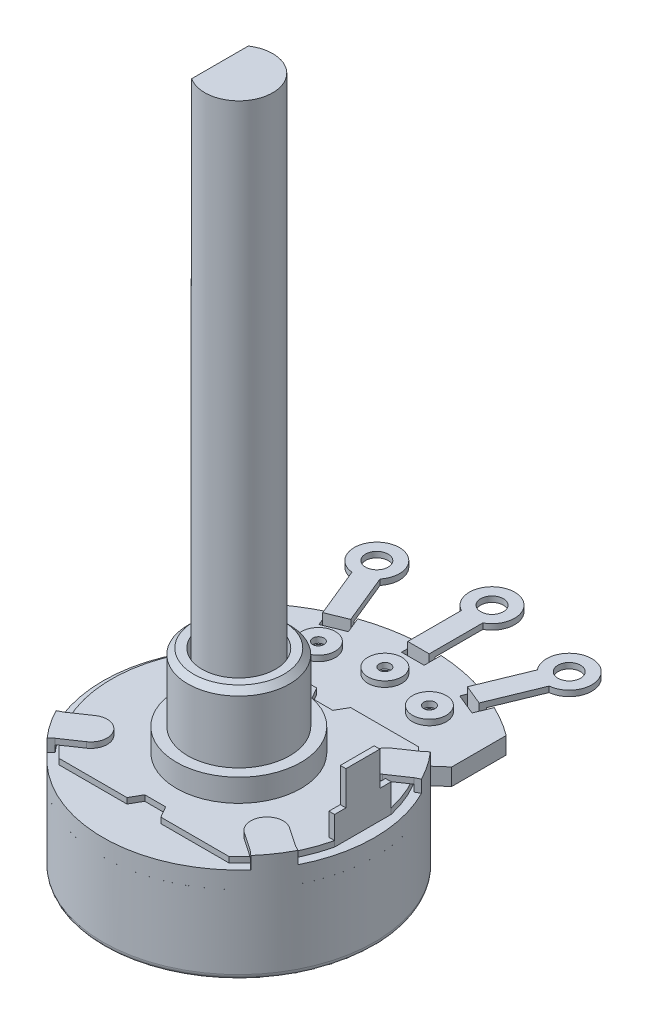
from build123d import *
from build123d.topology import SkipClean

# Parameters (mm, degrees)
SKETCH1_R                 = 12
BOSS_EXTRUDE1_DEPTH       = 7
SKETCH2_R                 = 11.5
CUT_EXTRUDE1_DEPTH        = 6.5
CUT_EXTRUDE2_DEPTH        = 2
SKETCH10_R                = 0.5
BOSS_EXTRUDE2_DEPTH       = 1.5
BOSS_EXTRUDE3_DEPTH       = 2.6
FILLET1_R                 = 0.5
BOSS_EXTRUDE4_DEPTH       = 0.5
SKETCH15_W                = 0.5
SKETCH15_H                = 5
BOSS_EXTRUDE5_DEPTH       = 2
CUT_EXTRUDE7_DEPTH        = 0.51
SKETCH18_W                = 0.5
SKETCH18_H                = 3
BOSS_EXTRUDE6_DEPTH       = 3
SKETCH19_W                = 2.879262998
SKETCH19_H                = 0.5
BOSS_EXTRUDE7_DEPTH       = 2
BOSS_EXTRUDE7_DEPTH_BACK  = 0.25
BOSS_EXTRUDE8_DEPTH       = 0.5
SKETCH34_W                = 2.879262998
SKETCH34_H                = 0.5
BOSS_EXTRUDE18_DEPTH      = 2
BOSS_EXTRUDE18_DEPTH_BACK = 0.3
SKETCH35_W                = 2.879262998
SKETCH35_H                = 0.5
BOSS_EXTRUDE19_DEPTH      = 2
BOSS_EXTRUDE19_DEPTH_BACK = 0.25
SKETCH36_W                = 2.879262998
SKETCH36_H                = 0.5
BOSS_EXTRUDE20_DEPTH      = 0.25
BOSS_EXTRUDE20_DEPTH_BACK = 2
BOSS_EXTRUDE21_DEPTH      = 0.5
SKETCH22_R                = 5.5
BOSS_EXTRUDE9_DEPTH       = 2
SKETCH23_R                = 4.5
SKETCH23_R_2              = 3.25
BOSS_EXTRUDE10_DEPTH      = 6
CHAMFER1_SIZE             = 0.5
SKETCH24_R                = 3
BOSS_EXTRUDE11_DEPTH      = 50
CUT_EXTRUDE8_DEPTH        = 16
BOSS_EXTRUDE12_DEPTH      = 0.5
SKETCH27_W                = 1.9
SKETCH27_H                = 0.5
BOSS_EXTRUDE13_DEPTH      = 2.1
SKETCH28_W                = 1.9
SKETCH28_H                = 0.5
BOSS_EXTRUDE14_DEPTH      = 8
SKETCH29_W                = 1.9
SKETCH29_H                = 0.5
BOSS_EXTRUDE15_DEPTH      = 8
SKETCH30_W                = 1.9
SKETCH30_H                = 0.5
BOSS_EXTRUDE16_DEPTH      = 8
SKETCH31_R                = 2
SKETCH31_R_2              = 1.5
SKETCH31_R_3              = 0.5
BOSS_EXTRUDE17_DEPTH      = 0.5
SKETCH33_R                = 1
SKETCH33_R_2              = 0.5
CUT_EXTRUDE9_DEPTH        = 59.592949152


with BuildPart() as part:
    # Sketch1 → Boss-Extrude1 (new body)
    with BuildSketch(Plane(origin=(0, 0, 0), x_dir=(1, 0, 0), z_dir=(0, 1, 0))):
        with Locations(Location((0, 0, 0), (0, 0, 270))):
            Circle(SKETCH1_R)
    extrude(amount=BOSS_EXTRUDE1_DEPTH)

    # Sketch2 → Cut-Extrude1 (cut)
    with BuildSketch(Plane(origin=(0, 7, 0), x_dir=(1, 0, 0), z_dir=(0, 1, 0))):
        with Locations(Location((0, 0, 0), (0, 0, 270))):
            Circle(SKETCH2_R)
    extrude(amount=-CUT_EXTRUDE1_DEPTH, mode=Mode.SUBTRACT)

    # Sketch3 → Cut-Extrude2 (cut)
    with BuildSketch(Plane(origin=(0, 7, 0), x_dir=(1, 0, 0), z_dir=(0, 1, 0))):
        with BuildLine():
            Line((-9, 7.937253933), (0, 0))
            Line((0, 0), (9, 7.937253933))
            ThreePointArc((9, 7.937253933), (0, 12), (-9, 7.937253933))
        make_face()
    extrude(amount=-CUT_EXTRUDE2_DEPTH, mode=Mode.SUBTRACT)



with BuildPart() as body_2:
    # Sketch10 → Boss-Extrude2 (new body)
    with BuildSketch(Plane(origin=(0, 7.001, 0), x_dir=(1, 0, 0), z_dir=(0, 1, 0))):
        with BuildLine():
            Line((-10.2421875, 5.229492826), (-10.6875, 5.456862079))
            ThreePointArc((-10.6875, 5.456862079), (-12, 0), (-10.6875, -5.456862079))
            Line((-10.6875, -5.456862079), (-10.2421875, -5.229492826))
            ThreePointArc((-10.2421875, -5.229492826), (-9.508168774, -6.46875), (-8.625, -7.606535019))
            Line((-8.625, -7.606535019), (-9, -7.937253933))
            ThreePointArc((-9, -7.937253933), (0, -12), (9, -7.937253933))
            Line((9, -7.937253933), (8.625, -7.606535019))
            ThreePointArc((8.625, -7.606535019), (9.508168774, -6.46875), (10.2421875, -5.229492826))
            Line((10.2421875, -5.229492826), (10.6875, -5.456862079))
            ThreePointArc((10.6875, -5.456862079), (12, 0), (10.6875, 5.456862079))
            Line((10.6875, 5.456862079), (10.2421875, 5.229492826))
            ThreePointArc((10.2421875, 5.229492826), (9.508168774, 6.46875), (8.625, 7.606535019))
            Line((8.625, 7.606535019), (9, 7.937253933))
            Line((9, 7.937253933), (10, 8.819171037))
            Line((10, 8.819171037), (10, 13.6383453))
            ThreePointArc((10, 13.6383453), (8.706156522, 14.498527551), (7.33883105, 15.236338843))
            Line((7.33883105, 15.236338843), (6.768953445, 13.848808838))
            Line((6.768953445, 13.848808838), (4.918913438, 14.608645644))
            Line((4.918913438, 14.608645644), (5.488791042, 15.99617565))
            ThreePointArc((5.488791042, 15.99617565), (3.274493365, 16.591629086), (1, 16.882075184))
            Line((1, 16.882075184), (1, 15.382075184))
            Line((1, 15.382075184), (-1, 15.382075184))
            Line((-1, 15.382075184), (-1, 16.882075184))
            ThreePointArc((-1, 16.882075184), (-3.274493365, 16.591629086), (-5.488791042, 15.99617565))
            Line((-5.488791042, 15.99617565), (-4.918913438, 14.608645644))
            Line((-4.918913438, 14.608645644), (-6.768953445, 13.848808838))
            Line((-6.768953445, 13.848808838), (-7.33883105, 15.236338843))
            ThreePointArc((-7.33883105, 15.236338843), (-8.706156522, 14.498527551), (-10, 13.6383453))
            Line((-10, 13.6383453), (-10, 8.819171037))
            Line((-10, 8.819171037), (-9, 7.937253933))
            Line((-9, 7.937253933), (-8.625, 7.606535019))
            ThreePointArc((-8.625, 7.606535019), (-9.508168774, 6.46875), (-10.2421875, 5.229492826))
        make_face()
        with Locations(Location((0, 12.911666462, 0), (0, 0, 270))):
            Circle(SKETCH10_R, mode=Mode.SUBTRACT)
        with Locations(Location((-4.905379704, 11.943549756, 0), (0, 0, 270))):
            Circle(SKETCH10_R, mode=Mode.SUBTRACT)
        with Locations(Location((4.905379704, 11.943549756, 0), (0, 0, 270))):
            Circle(SKETCH10_R, mode=Mode.SUBTRACT)
    extrude(amount=BOSS_EXTRUDE2_DEPTH)


with BuildPart() as part_1:
    with SkipClean():  # the faces are left unmerged after this step: merging them gives an invalid solid
        add(part.part)

        add(body_2.part)  # Boss-Extrude3 merges body 2
        # Sketch11 → Boss-Extrude3 (add)
        with BuildSketch(Plane(origin=(0, 7, 0), x_dir=(1, 0, 0), z_dir=(0, 1, 0))):
            with BuildLine():
                Line((8.625, 7.606535019), (9, 7.937253933))
                ThreePointArc((9, 7.937253933), (9.922828246, 6.748146383), (10.689538103, 5.452868525))
                Line((10.689538103, 5.452868525), (10.244140682, 5.225665669))
                ThreePointArc((10.244140682, 5.225665669), (9.509377069, 6.466973617), (8.625, 7.606535019))
            make_face()
            with BuildLine():
                Line((8.625, -7.606535019), (9, -7.937253933))
                ThreePointArc((9, -7.937253933), (9.922828246, -6.748146383), (10.689538103, -5.452868525))
                Line((10.689538103, -5.452868525), (10.244140682, -5.225665669))
                ThreePointArc((10.244140682, -5.225665669), (9.509377069, -6.466973617), (8.625, -7.606535019))
            make_face()
            with BuildLine():
                Line((-8.625, -7.606535019), (-9, -7.937253933))
                ThreePointArc((-9, -7.937253933), (-9.922828246, -6.748146383), (-10.689538103, -5.452868525))
                Line((-10.689538103, -5.452868525), (-10.244140682, -5.225665669))
                ThreePointArc((-10.244140682, -5.225665669), (-9.509377069, -6.466973617), (-8.625, -7.606535019))
            make_face()
            with BuildLine():
                Line((-10.689538103, 5.452868525), (-10.244140682, 5.225665669))
                ThreePointArc((-10.244140682, 5.225665669), (-9.509377069, 6.466973617), (-8.625, 7.606535019))
                Line((-8.625, 7.606535019), (-9, 7.937253933))
                ThreePointArc((-9, 7.937253933), (-9.922828246, 6.748146383), (-10.689538103, 5.452868525))
            make_face()
        extrude(amount=BOSS_EXTRUDE3_DEPTH)

    # Fillet1
    fillet1_edges = [part_1.edges().sort_by_distance(p)[0] for p in [
        (0, 0, -12),
    ]]
    fillet(fillet1_edges, radius=FILLET1_R)



with BuildPart() as body_2_2:
    # Sketch14 → Boss-Extrude4 (new body)
    with BuildSketch(Plane(origin=(0, 8.511, 0), x_dir=(1, 0, 0), z_dir=(0, 1, 0))):
        with BuildLine():
            Line((-7.5, 8.385254916), (-1.5, 8.385254916))
            Line((-1.5, 8.385254916), (-0.922649731, 7.385254916))
            Line((-0.922649731, 7.385254916), (0.922649731, 7.385254916))
            Line((0.922649731, 7.385254916), (1.5, 8.385254916))
            Line((1.5, 8.385254916), (7.5, 8.385254916))
            ThreePointArc((7.5, 8.385254916), (11.25, 0), (7.5, -8.385254916))
            Line((7.5, -8.385254916), (1.5, -8.385254916))
            Line((1.5, -8.385254916), (0.922649731, -7.385254916))
            Line((0.922649731, -7.385254916), (-0.922649731, -7.385254916))
            Line((-0.922649731, -7.385254916), (-1.5, -8.385254916))
            Line((-1.5, -8.385254916), (-7.5, -8.385254916))
            ThreePointArc((-7.5, -8.385254916), (-11.25, 0), (-7.5, 8.385254916))
        make_face()
    extrude(amount=BOSS_EXTRUDE4_DEPTH)

    # Sketch15 → Boss-Extrude5 (add)
    with BuildSketch(Plane(origin=(0, 9.011, 0), x_dir=(1, 0, 0), z_dir=(0, 1, 0))):
        with Locations((10.718705484, 0)):
            Rectangle(SKETCH15_W, SKETCH15_H)
    extrude(amount=BOSS_EXTRUDE5_DEPTH)

    # Sketch17 → Cut-Extrude7 (cut)
    with BuildSketch(Plane(origin=(0, 9.011, 0), x_dir=(1, 0, 0), z_dir=(0, 1, 0))):
        Polygon((10.968705484, 72.60744613), (10.968705484, 2.5), (10.968705484, -2.5), (10.968705484, -72.60744613), (151.183597744, -72.60744613), (151.183597744, 72.60744613), align=None)
    extrude(amount=-CUT_EXTRUDE7_DEPTH, mode=Mode.SUBTRACT)

    # Sketch18 → Boss-Extrude6 (add)
    with BuildSketch(Plane(origin=(0, 11.011, 0), x_dir=(1, 0, 0), z_dir=(0, 1, 0))):
        with Locations((10.718705484, 0)):
            Rectangle(SKETCH18_W, SKETCH18_H)
    extrude(amount=BOSS_EXTRUDE6_DEPTH)

    # Sketch22 → Boss-Extrude9 (add)
    with BuildSketch(Plane(origin=(0, 9.011, 0), x_dir=(1, 0, 0), z_dir=(0, 1, 0))):
        with Locations(Location((0, 0, 0), (0, 0, 270))):
            Circle(SKETCH22_R)
    extrude(amount=BOSS_EXTRUDE9_DEPTH)

    # Sketch23 → Boss-Extrude10 (add)
    with BuildSketch(Plane(origin=(0, 11.011, 0), x_dir=(1, 0, 0), z_dir=(0, 1, 0))):
        with Locations(Location((0, 0, 0), (0, 0, 270))):
            Circle(SKETCH23_R)
        with Locations(Location((0, 0, 0), (0, 0, 270))):
            Circle(SKETCH23_R_2, mode=Mode.SUBTRACT)
    extrude(amount=BOSS_EXTRUDE10_DEPTH)

    # Chamfer1
    chamfer1_edges = [body_2_2.edges().sort_by_distance(p)[0] for p in [
        (0, 17.011, -4.5),
    ]]
    chamfer(chamfer1_edges, length=CHAMFER1_SIZE)

    # Sketch24 → Boss-Extrude11 (add)
    with BuildSketch(Plane(origin=(0, 11.011, 0), x_dir=(1, 0, 0), z_dir=(0, 1, 0))):
        with Locations(Location((0, 0, 0), (0, 0, 270))):
            Circle(SKETCH24_R)
    extrude(amount=BOSS_EXTRUDE11_DEPTH)

    # Sketch25 → Cut-Extrude8 (cut)
    with BuildSketch(Plane(origin=(0, 61.011, 0), x_dir=(1, 0, 0), z_dir=(0, 1, 0))):
        with BuildLine():
            Line((-1.658312395, 2.5), (-1.658312395, -2.5))
            ThreePointArc((-1.658312395, -2.5), (-3, 0), (-1.658312395, 2.5))
        make_face()
    extrude(amount=-CUT_EXTRUDE8_DEPTH, mode=Mode.SUBTRACT)


with BuildPart() as body_3:
    # Sketch19 → Boss-Extrude7 (new, two sides)
    with BuildSketch(Plane(origin=(9.434570341, 0, 6.416100344), x_dir=(-0.5623455319339524, 0, 0.8269023537963356), z_dir=(-0.8269023537963356, 0, -0.5623455319339524))) as boss_extrude7_sk:
        with Locations((0, 9.35)):
            Rectangle(SKETCH19_W, SKETCH19_H)
    extrude(amount=BOSS_EXTRUDE7_DEPTH)
    extrude(boss_extrude7_sk.sketch, amount=-BOSS_EXTRUDE7_DEPTH_BACK)


with BuildPart() as part_2:
    with SkipClean():  # the faces are left unmerged after this step: merging them gives an invalid solid
        add(part_1.part)

        add(body_3.part)  # Boss-Extrude8 merges body 3
        # Sketch21 → Boss-Extrude8 (add)
        with BuildSketch(Plane(origin=(0, 9.6, 0), x_dir=(1, 0, 0), z_dir=(0, 1, 0))):
            with BuildLine():
                Line((8.590335974, -4.100974606), (6.971195292, -6.481843955))
                ThreePointArc((6.971195292, -6.481843955), (6.590330958, -4.48183894), (8.590335974, -4.100974606))
            make_face()
        extrude(amount=-BOSS_EXTRUDE8_DEPTH)

    # Sketch35 → Boss-Extrude19 (add, two sides)
    with BuildSketch(Plane(origin=(9.434570341, 0, -6.416100344), x_dir=(0.562345531933952, 0, 0.8269023537963359), z_dir=(-0.826902353796336, 1.3052292315477542e-15, 0.562345531933952))) as boss_extrude19_sk:
        with Locations((0, 9.35)):
            Rectangle(SKETCH35_W, SKETCH35_H)
    extrude(amount=BOSS_EXTRUDE19_DEPTH)
    extrude(boss_extrude19_sk.sketch, amount=-BOSS_EXTRUDE19_DEPTH_BACK)

    # Sketch36 → Boss-Extrude20 (add, two sides)
    with BuildSketch(Plane(origin=(-9.434570341, 0, 6.416100344), x_dir=(0.562345531933952, 0, 0.8269023537963359), z_dir=(-0.826902353796336, 0, 0.562345531933952))) as boss_extrude20_sk:
        with Locations((0, 9.35)):
            Rectangle(SKETCH36_W, SKETCH36_H)
    extrude(amount=BOSS_EXTRUDE20_DEPTH)
    extrude(boss_extrude20_sk.sketch, amount=-BOSS_EXTRUDE20_DEPTH_BACK)



with BuildPart() as body_3_2:
    # Sketch34 → Boss-Extrude18 (new, two sides)
    with BuildSketch(Plane(origin=(-9.434570341, 0, -6.416100344), x_dir=(0.5623455319339522, 0, -0.8269023537963357), z_dir=(0.8269023537963357, 0, 0.5623455319339522))) as boss_extrude18_sk:
        with Locations((0, 9.35)):
            Rectangle(SKETCH34_W, SKETCH34_H)
    extrude(amount=BOSS_EXTRUDE18_DEPTH)
    extrude(boss_extrude18_sk.sketch, amount=-BOSS_EXTRUDE18_DEPTH_BACK)


with BuildPart() as part_3:
    add(part_2.part)

    add(body_3_2.part)  # Boss-Extrude21 merges body 3 2
    # Sketch37 → Boss-Extrude21 (add)
    with BuildSketch(Plane(origin=(0, 9.6, 0), x_dir=(1, 0, 0), z_dir=(0, 1, 0))):
        with BuildLine():
            Line((6.971195292, 6.481843955), (8.590335974, 4.100974606))
            ThreePointArc((8.590335974, 4.100974606), (6.590330958, 4.48183894), (6.971195292, 6.481843955))
        make_face()
        with BuildLine():
            Line((-6.971195292, 6.481843955), (-8.590335974, 4.100974606))
            ThreePointArc((-8.590335974, 4.100974606), (-6.590330958, 4.48183894), (-6.971195292, 6.481843955))
        make_face()
        with BuildLine():
            Line((-8.590335974, -4.100974606), (-6.971195292, -6.481843955))
            ThreePointArc((-6.971195292, -6.481843955), (-6.590330958, -4.48183894), (-8.590335974, -4.100974606))
        make_face()
    extrude(amount=-BOSS_EXTRUDE21_DEPTH)

    # Sketch26 → Boss-Extrude12 (add)
    with BuildSketch(Plane.XZ.offset(-7.001)):
        with BuildLine():
            Line((-5.784148708, -11.582627273), (-7.102620848, -14.792824762))
            Line((-7.102620848, -14.792824762), (-5.345082841, -15.514669728))
            Line((-5.345082841, -15.514669728), (-4.026610701, -12.304472239))
            ThreePointArc((-4.026610701, -12.304472239), (-4.544457221, -11.064780753), (-5.784148708, -11.582627273))
        make_face()
        with BuildLine():
            Line((-0.95, -12.911666462), (-0.95, -16.382075184))
            Line((-0.95, -16.382075184), (0.95, -16.382075184))
            Line((0.95, -16.382075184), (0.95, -12.911666462))
            ThreePointArc((0.95, -12.911666462), (0, -11.961666462), (-0.95, -12.911666462))
        make_face()
        with BuildLine():
            Line((4.026610701, -12.304472239), (5.345082841, -15.514669728))
            Line((5.345082841, -15.514669728), (7.102620848, -14.792824762))
            Line((7.102620848, -14.792824762), (5.784148708, -11.582627273))
            ThreePointArc((5.784148708, -11.582627273), (4.544457221, -11.064780753), (4.026610701, -12.304472239))
        make_face()
    extrude(amount=BOSS_EXTRUDE12_DEPTH)

    # Sketch27 → Boss-Extrude13 (add)
    with BuildSketch(Plane(origin=(0, 7.001, 0), x_dir=(1, 0, 0), z_dir=(0, 1, 0))):
        with Locations((0, 16.132075184)):
            Rectangle(SKETCH27_W, SKETCH27_H)
        Polygon((-5.345082841, 15.514669728), (-5.155123639, 15.052159726), (-6.912661646, 14.33031476), (-7.102620848, 14.792824762), align=None)
        Polygon((7.102620848, 14.792824762), (6.912661646, 14.33031476), (5.155123639, 15.052159726), (5.345082841, 15.514669728), align=None)
    extrude(amount=BOSS_EXTRUDE13_DEPTH)

    # Sketch28 → Boss-Extrude14 (add)
    with BuildSketch(Plane(origin=(6.223851844, 0, -15.153747245), x_dir=(-0.9250200035365485, 0, -0.37991840315684094), z_dir=(0.379918403156841, 0, -0.9250200035365486))):
        with Locations((0, 8.851)):
            Rectangle(SKETCH28_W, SKETCH28_H)
    extrude(amount=BOSS_EXTRUDE14_DEPTH)

    # Sketch29 → Boss-Extrude15 (add)
    with BuildSketch(Plane(origin=(0, 0, -16.382075184), x_dir=(-1, 0, 0), z_dir=(0, 0, -1))):
        with Locations((0, 8.851)):
            Rectangle(SKETCH29_W, SKETCH29_H)
    extrude(amount=BOSS_EXTRUDE15_DEPTH)

    # Sketch30 → Boss-Extrude16 (add)
    with BuildSketch(Plane(origin=(-6.223851844, 0, -15.153747245), x_dir=(-0.9250200035365496, 0, 0.3799184031568382), z_dir=(-0.3799184031568382, 0, -0.9250200035365496))):
        with Locations((0, 8.851)):
            Rectangle(SKETCH30_W, SKETCH30_H)
    extrude(amount=BOSS_EXTRUDE16_DEPTH)

    # Sketch31 → Boss-Extrude17 (add)
    with BuildSketch(Plane(origin=(0, 9.101, 0), x_dir=(1, 0, 0), z_dir=(0, 1, 0))):
        with Locations((8.503362263, 20.703867266)):
            Circle(SKETCH31_R)
        with Locations((0, 22.382075184)):
            Circle(SKETCH31_R)
        with Locations((-8.503362263, 20.703867266)):
            Circle(SKETCH31_R)
        with Locations(Location((-4.905379704, 11.943549756, 0), (0, 0, 270))):
            Circle(SKETCH31_R_2)
        with Locations(Location((-4.905379704, 11.943549756, 0), (0, 0, 270))):
            Circle(SKETCH31_R_3, mode=Mode.SUBTRACT)
        with Locations(Location((0, 12.911666462, 0), (0, 0, 270))):
            Circle(SKETCH31_R_2)
        with Locations(Location((0, 12.911666462, 0), (0, 0, 270))):
            Circle(SKETCH31_R_3, mode=Mode.SUBTRACT)
        with Locations(Location((4.905379704, 11.943549756, 0), (0, 0, 270))):
            Circle(SKETCH31_R_2)
        with Locations(Location((4.905379704, 11.943549756, 0), (0, 0, 270))):
            Circle(SKETCH31_R_3, mode=Mode.SUBTRACT)
    extrude(amount=-BOSS_EXTRUDE17_DEPTH)


with BuildPart() as boss_extrude17_piece_1:
    # of the separate pieces the step leaves, piece 1, a body of its own (boss_extrude17_pieces)
    add(part_3.part.solids().sort_by_distance((-6.971195292, 9.6, -6.481843955))[0])

    # Sketch33 → Cut-Extrude9 (cut, through all)
    with BuildSketch(Plane(origin=(0, 9.101, 0), x_dir=(1, 0, 0), z_dir=(0, 1, 0))):
        with Locations(Location((-8.503362263, 20.703867266, 0), (0, 0, 270))):
            Circle(SKETCH33_R)
        with BuildLine():
            Line((-10.141968073, 22.19298479), (-10.050776863, 21.97095371))
            ThreePointArc((-10.050776863, 21.97095371), (-9.693240824, 22.31140856), (-9.263199081, 22.553907269))
            Line((-9.263199081, 22.553907269), (-10.141968073, 22.19298479))
        make_face()
        with BuildLine():
            Line((-8.384430066, 22.914829756), (-9.263199081, 22.553907269))
            ThreePointArc((-9.263199081, 22.553907269), (-8.78685638, 22.683673086), (-8.293238856, 22.692798676))
            Line((-8.293238856, 22.692798676), (-8.384430066, 22.914829756))
        make_face()
        with Locations(Location((0, 22.382075184, 0), (0, 0, 270))):
            Circle(SKETCH33_R)
        with Locations(Location((8.503362263, 20.703867266, 0), (0, 0, 270))):
            Circle(SKETCH33_R)
        with BuildLine():
            Line((8.384430066, 22.914829756), (8.293238856, 22.692798676))
            ThreePointArc((8.293238856, 22.692798676), (8.786856339, 22.683673092), (9.263199005, 22.5539073))
            Line((9.263199005, 22.5539073), (8.384430066, 22.914829756))
        make_face()
        with BuildLine():
            Line((10.141968073, 22.19298479), (9.263199005, 22.5539073))
            ThreePointArc((9.263199005, 22.5539073), (9.693240791, 22.311408584), (10.050776863, 21.97095371))
            Line((10.050776863, 21.97095371), (10.141968073, 22.19298479))
        make_face()
        with BuildLine():
            Line((0.95, 24.382075184), (0, 24.382075184))
            ThreePointArc((0, 24.382075184), (0.489926943, 24.321139802), (0.95, 24.142046775))
            Line((0.95, 24.142046775), (0.95, 24.382075184))
        make_face()
        with BuildLine():
            Line((-0.95, 24.382075184), (-0.95, 24.142046775))
            ThreePointArc((-0.95, 24.142046775), (-0.489926943, 24.321139802), (0, 24.382075184))
            Line((0, 24.382075184), (-0.95, 24.382075184))
        make_face()
        with Locations(Location((0, 12.911666462, 0), (0, 0, 270))):
            Circle(SKETCH33_R_2)
        with Locations(Location((4.905379704, 11.943549756, 0), (0, 0, 270))):
            Circle(SKETCH33_R_2)
        with Locations(Location((-4.905379704, 11.943549756, 0), (0, 0, 270))):
            Circle(SKETCH33_R_2)
    extrude(amount=-CUT_EXTRUDE9_DEPTH, mode=Mode.SUBTRACT)


with BuildPart() as boss_extrude17_piece_2:
    # of the separate pieces the step leaves, piece 2, a body of its own (boss_extrude17_pieces)
    add(part_3.part.solids().sort_by_distance((0, 9.101, -11.411666462))[0])


with BuildPart() as boss_extrude17_piece_3:
    # of the separate pieces the step leaves, piece 3, a body of its own (boss_extrude17_pieces)
    add(part_3.part.solids().sort_by_distance((-4.905379704, 9.101, -10.443549756))[0])


with BuildPart() as boss_extrude17_piece_4:
    # of the separate pieces the step leaves, piece 4, a body of its own (boss_extrude17_pieces)
    add(part_3.part.solids().sort_by_distance((4.905379704, 9.101, -10.443549756))[0])


solid = Compound([body_2_2.part, boss_extrude17_piece_1.part, boss_extrude17_piece_2.part, boss_extrude17_piece_3.part, boss_extrude17_piece_4.part])
